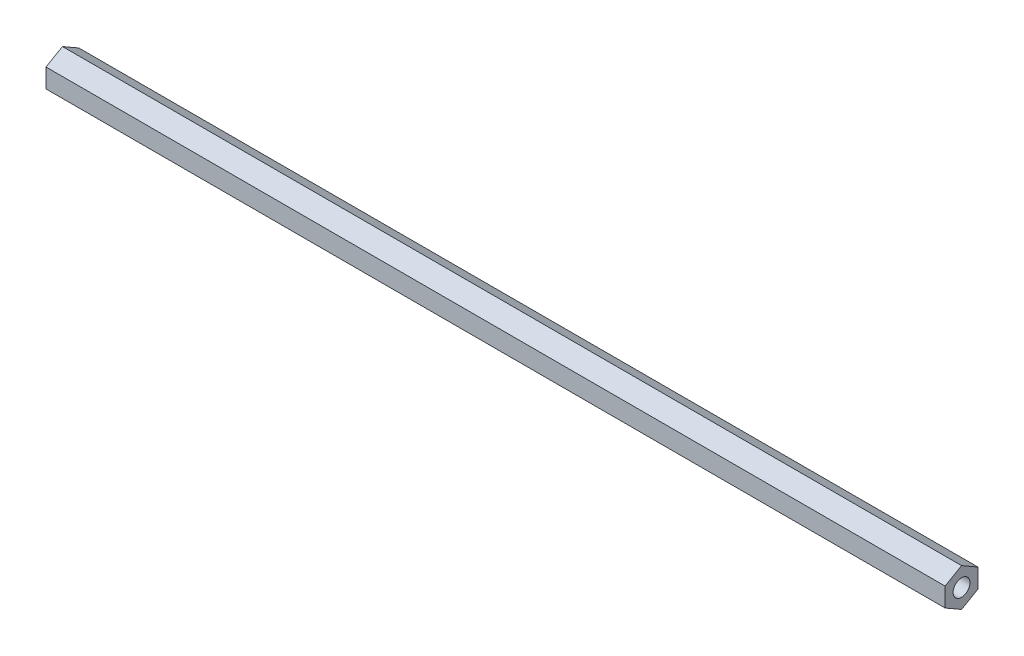
from build123d import *

# Parameters (mm, degrees)
BOSS_EXTRUDE1_DEPTH = 346.86875
SKETCH2_R           = 3.2639
CUT_EXTRUDE1_DEPTH  = 12.7
SKETCH3_R           = 3.2639
CUT_EXTRUDE2_DEPTH  = 12.7


with BuildPart() as part:
    # Sketch1 → Boss-Extrude1 (new body)
    with BuildSketch(Plane(origin=(0, 0, 0), x_dir=(0, 0, -1), z_dir=(1, 0, 0))):
        Polygon((0, 7.332348419), (-6.35, 3.666174209), (-6.35, -3.666174209), (0, -7.332348419), (6.35, -3.666174209), (6.35, 3.666174209), align=None)
    extrude(amount=BOSS_EXTRUDE1_DEPTH)

    # Sketch2 → Cut-Extrude1 (cut)
    with BuildSketch(Plane(origin=(346.86875, 0, 0), x_dir=(0, 0, -1), z_dir=(1, 0, 0))):
        Circle(SKETCH2_R)
    extrude(amount=-CUT_EXTRUDE1_DEPTH, mode=Mode.SUBTRACT)

    # Sketch3 → Cut-Extrude2 (cut)
    with BuildSketch(Plane.ZY):
        Circle(SKETCH3_R)
    extrude(amount=-CUT_EXTRUDE2_DEPTH, mode=Mode.SUBTRACT)


solid = part.part
